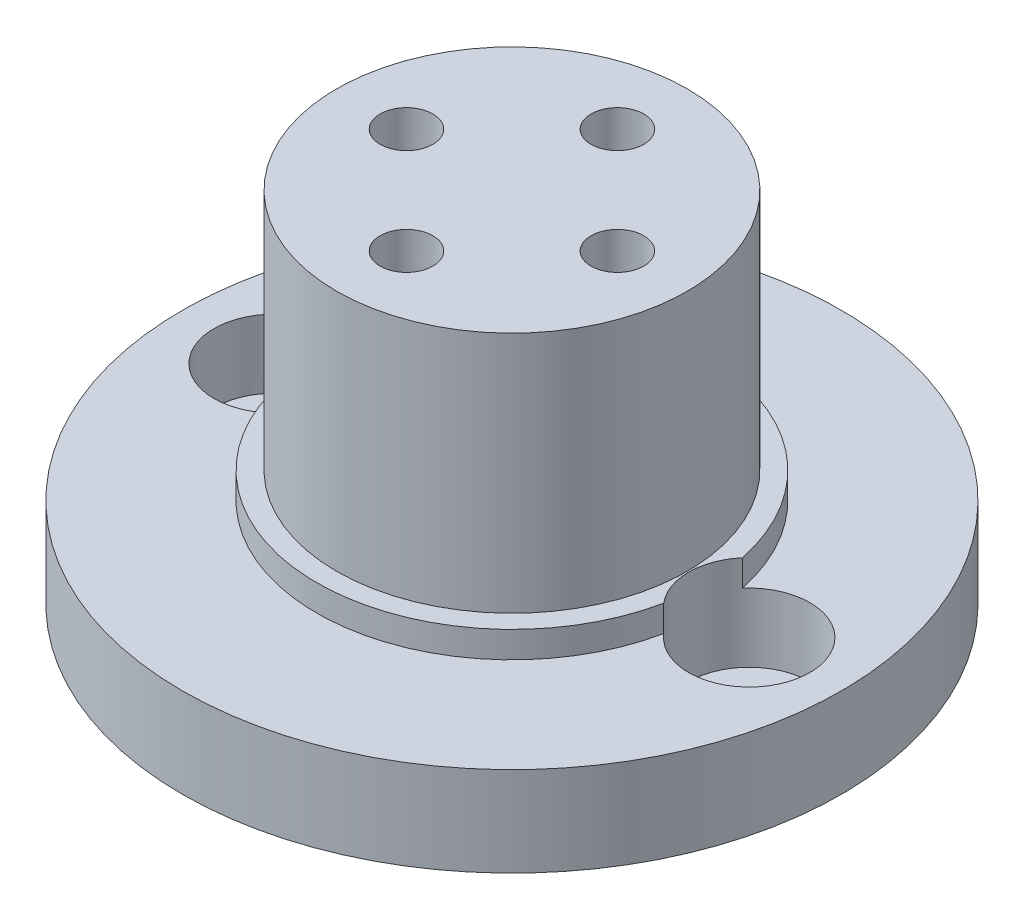
from build123d import *

# Parameters (mm, degrees)
SKETCH1_R               = 15.875
BOSS_EXTRUDE1_DEPTH     = 4.318
SKETCH4_R               = 9.398
BOSS_EXTRUDE2_DEPTH     = 12.954
SKETCH5_R               = 2.921
CUT_EXTRUDE1_DEPTH      = 26.919825732
CUT_EXTRUDE1_DEPTH_BACK = 3.302
SKETCH6_R               = 1.4605
SKETCH6_R_2             = 1.73706236
CUT_EXTRUDE2_DEPTH      = 26.919825732
CUT_EXTRUDE2_DEPTH_BACK = 26.919825732
SKETCH10_R              = 1.27
CUT_EXTRUDE6_DEPTH      = 29.325840394
SKETCH12_R              = 9.398
SKETCH12_R_2            = 8.4455
CUT_EXTRUDE8_DEPTH      = 11.684
CUT_EXTRUDE9_DEPTH      = 10.16


with BuildPart() as part:
    # Sketch1 → Boss-Extrude1 (new body)
    with BuildSketch(Plane(origin=(0, 0, 0), x_dir=(1, 0, 0), z_dir=(0, 1, 0))):
        with Locations(Location((0, 0, 0), (0, 0, 270))):
            Circle(SKETCH1_R)
    extrude(amount=BOSS_EXTRUDE1_DEPTH)

    # Sketch4 → Boss-Extrude2 (add)
    with BuildSketch(Plane(origin=(0, 4.318, 0), x_dir=(1, 0, 0), z_dir=(0, 1, 0))):
        with Locations(Location((0, 0, 0), (0, 0, 270))):
            Circle(SKETCH4_R)
    extrude(amount=BOSS_EXTRUDE2_DEPTH)

    # Sketch5 → Cut-Extrude1 (cut, two sides)
    with BuildSketch(Plane(origin=(0, 4.318, 0), x_dir=(1, 0, 0), z_dir=(0, 1, 0))) as cut_extrude1_sk:
        with Locations(Location((-11.43, 0, 0), (0, 0, 40.395058429))):
            Circle(SKETCH5_R)
        with Locations(Location((11.43, 0, 0), (0, 0, 139.604941571))):
            Circle(SKETCH5_R)
    extrude(amount=CUT_EXTRUDE1_DEPTH, mode=Mode.SUBTRACT)
    extrude(cut_extrude1_sk.sketch, amount=-CUT_EXTRUDE1_DEPTH_BACK, mode=Mode.SUBTRACT)

    # Sketch6 → Cut-Extrude2 (cut, two sides)
    with BuildSketch(Plane(origin=(0, 4.318, 0), x_dir=(1, 0, 0), z_dir=(0, 1, 0))) as cut_extrude2_sk:
        with Locations(Location((-11.43, 0, 0), (0, 0, 270))):
            Circle(SKETCH6_R)
        with Locations(Location((11.43, 0, 0), (0, 0, 270))):
            Circle(SKETCH6_R_2)
    extrude(amount=CUT_EXTRUDE2_DEPTH, mode=Mode.SUBTRACT)
    extrude(cut_extrude2_sk.sketch, amount=-CUT_EXTRUDE2_DEPTH_BACK, mode=Mode.SUBTRACT)

    # Sketch10 → Cut-Extrude6 (cut, through all)
    with BuildSketch(Plane(origin=(0, 17.272, 0), x_dir=(1, 0, 0), z_dir=(0, 1, 0))):
        with Locations(Location((0, 5.08, 0), (0, 0, 270))):
            Circle(SKETCH10_R)
        with Locations(Location((0, -5.08, 0), (0, 0, 270))):
            Circle(SKETCH10_R)
        with Locations(Location((5.08, 0, 0), (0, 0, 270))):
            Circle(SKETCH10_R)
        with Locations(Location((-5.08, 0, 0), (0, 0, 270))):
            Circle(SKETCH10_R)
    extrude(amount=-CUT_EXTRUDE6_DEPTH, mode=Mode.SUBTRACT)

    # Sketch12 → Cut-Extrude8 (cut)
    with BuildSketch(Plane(origin=(0, 17.272, 0), x_dir=(1, 0, 0), z_dir=(0, 1, 0))):
        Circle(SKETCH12_R)
        with Locations(Location((0, 0, 0), (0, 0, 270))):
            Circle(SKETCH12_R_2, mode=Mode.SUBTRACT)
    extrude(amount=-CUT_EXTRUDE8_DEPTH, mode=Mode.SUBTRACT)

    # Sketch13 → Cut-Extrude9 (cut)
    with BuildSketch(Plane.XZ):
        Polygon((7.426351494, 0), (6.253175747, 2.032), (3.906824253, 2.032), (2.733648506, 0), (3.906824253, -2.032), (6.253175747, -2.032), align=None)
        Polygon((2.346351494, -5.08), (1.173175747, -3.048), (-1.173175747, -3.048), (-2.346351494, -5.08), (-1.173175747, -7.112), (1.173175747, -7.112), align=None)
        Polygon((-2.733648506, 0), (-3.906824253, 2.032), (-6.253175747, 2.032), (-7.426351494, 0), (-6.253175747, -2.032), (-3.906824253, -2.032), align=None)
        Polygon((2.346351494, 5.08), (1.173175747, 7.112), (-1.173175747, 7.112), (-2.346351494, 5.08), (-1.173175747, 3.048), (1.173175747, 3.048), align=None)
    extrude(amount=-CUT_EXTRUDE9_DEPTH, mode=Mode.SUBTRACT)


solid = part.part
